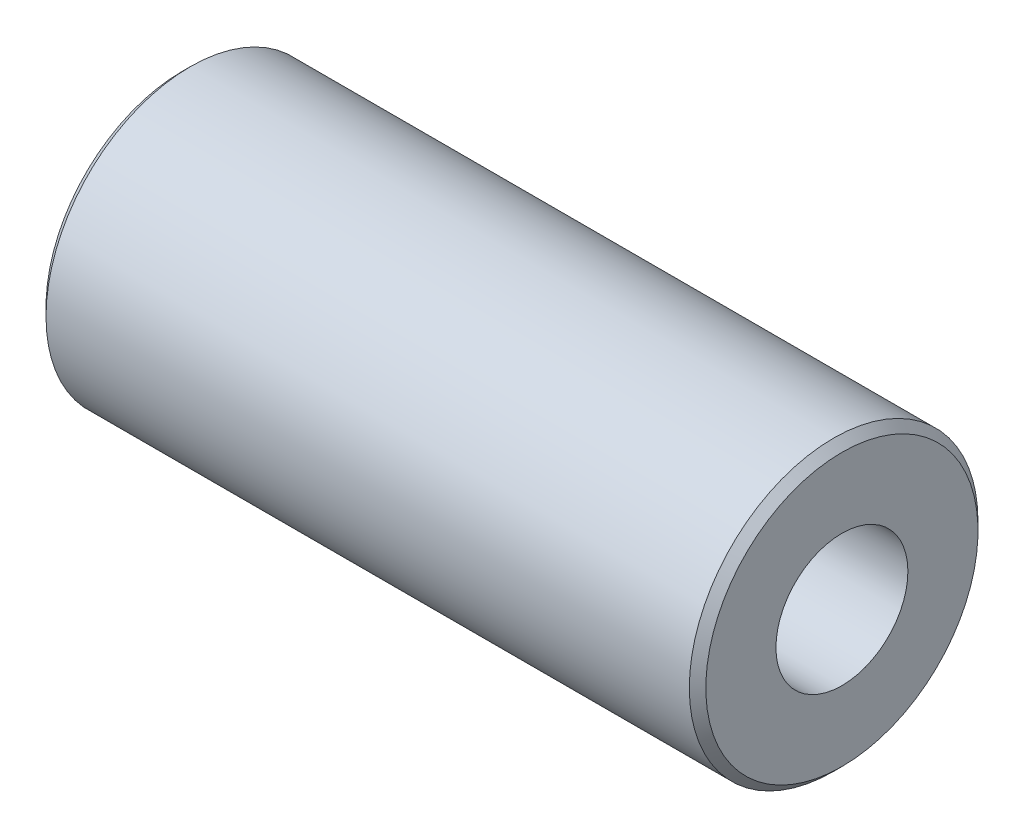
from build123d import *

# Parameters (mm, degrees)
SKETCH_1_W     = 8
SKETCH_1_H     = 1.75
CHAMFER_1_SIZE = 0.1


with BuildPart() as part:
    # 草图1 → 旋转1 (revolve)
    with BuildSketch(Plane.XY):
        with Locations((0, 0.875)):
            Rectangle(SKETCH_1_W, SKETCH_1_H)
    revolve(axis=Axis((-4, 0, 0), (1, 0, 0)))

    # 草图3 → Hole Wizard 380 (revolve, cut)
    with BuildSketch(Plane(origin=(-4, 0, 0), x_dir=(0, 0, 1), z_dir=(0, 1, 0))):
        Polygon((0, 0), (0, 6.480688495), (0.8, 6), (0.8, 0), align=None)
    hole_wizard_380 = revolve(axis=Axis((-10.35, 0, 0), (1, 0, 0)), mode=Mode.SUBTRACT)

    # 镜向1: Hole Wizard 380 across plane
    add(hole_wizard_380.mirror(Plane(origin=(0, 0, 0), x_dir=(0, 0, 1), z_dir=(1, 0, 0))), mode=Mode.SUBTRACT)

    # 倒角1
    chamfer_1_edges = [part.edges().sort_by_distance(p)[0] for p in [
        (-4, -1.75, 0),
        (4, -1.75, 0),
    ]]
    chamfer(chamfer_1_edges, length=CHAMFER_1_SIZE)


solid = part.part
